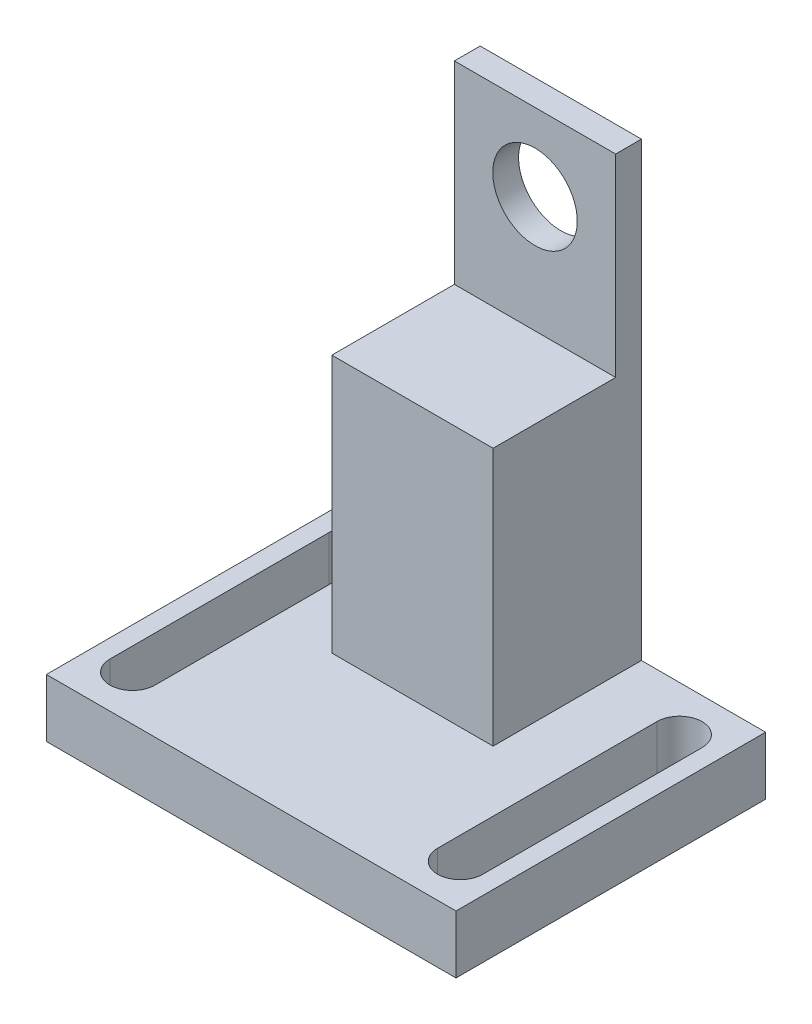
from build123d import *

# Parameters (mm, degrees)
SKETCH1_R           = 6.55
BOSS_EXTRUDE1_DEPTH = 11.5
SKETCH9_W           = 19
SKETCH9_H           = 30
CUT_EXTRUDE4_DEPTH  = 45.25
SKETCH12_W          = 63.5
SKETCH12_H          = 9
BOSS_EXTRUDE2_DEPTH = 25
CUT_EXTRUDE5_DEPTH  = 80


with BuildPart() as part:
    # Sketch1 → Boss-Extrude1 (new body, symmetric)
    with BuildSketch(Plane.XY):
        Polygon((-12.5, -58), (-31.75, -58), (-31.75, -67), (31.75, -67), (31.75, -58), (12.5, -58), (12.5, 12), (-12.5, 12), align=None)
        Circle(SKETCH1_R, mode=Mode.SUBTRACT)
    extrude(amount=BOSS_EXTRUDE1_DEPTH, both=True)

    # Sketch9 → Cut-Extrude4 (cut, through all)
    with BuildSketch(Plane.ZY.offset(12.5)):
        with Locations((2, -3)):
            Rectangle(SKETCH9_W, SKETCH9_H)
    extrude(amount=-CUT_EXTRUDE4_DEPTH, mode=Mode.SUBTRACT)

    # Sketch12 → Boss-Extrude2 (add)
    with BuildSketch(Plane.XY.offset(11.5)):
        with Locations((0, -62.5)):
            Rectangle(SKETCH12_W, SKETCH12_H)
    extrude(amount=BOSS_EXTRUDE2_DEPTH)

    # Sketch11 → Cut-Extrude5 (cut, through all)
    with BuildSketch(Plane.XZ.offset(67)):
        with BuildLine():
            Line((-21.9, 29.5), (-21.9, -4.5))
            ThreePointArc((-21.9, -4.5), (-25.4, -8), (-28.9, -4.5))
            Line((-28.9, -4.5), (-28.9, 29.5))
            ThreePointArc((-28.9, 29.5), (-25.4, 33), (-21.9, 29.5))
        make_face()
        with BuildLine():
            Line((21.9, -4.5), (21.9, 29.5))
            ThreePointArc((21.9, 29.5), (25.4, 33), (28.9, 29.5))
            Line((28.9, 29.5), (28.9, -4.5))
            ThreePointArc((28.9, -4.5), (25.4, -8), (21.9, -4.5))
        make_face()
    extrude(amount=-CUT_EXTRUDE5_DEPTH, mode=Mode.SUBTRACT)


solid = part.part
